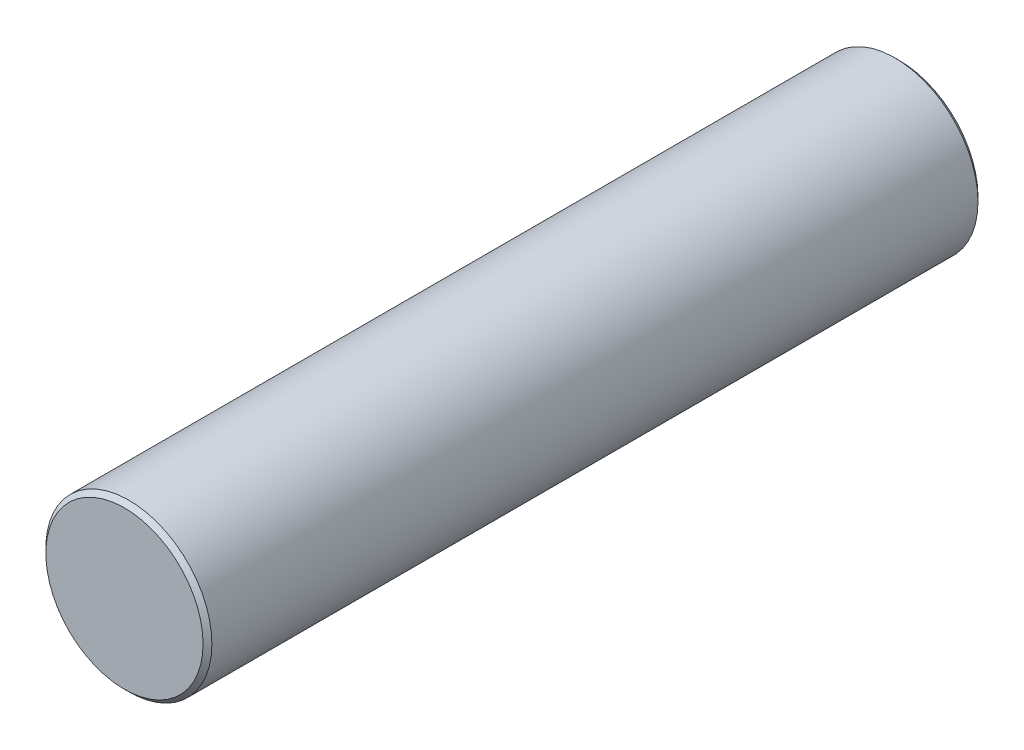
from build123d import *

# Parameters (mm, degrees)
SKETCH1_R      = 2.38125
EXTRUDE1_DEPTH = 22.225
CHAMFER1_SIZE  = 0.127


with BuildPart() as part:
    # Sketch1 → Extrude1 (new body)
    with BuildSketch(Plane.XY):
        Circle(SKETCH1_R)
    extrude(amount=-EXTRUDE1_DEPTH)

    # Chamfer1
    chamfer1_edges = [part.edges().sort_by_distance(p)[0] for p in [
        (-2.38125, 0, 0),
        (-2.38125, 0, -22.225),
    ]]
    chamfer(chamfer1_edges, length=CHAMFER1_SIZE)


solid = part.part
